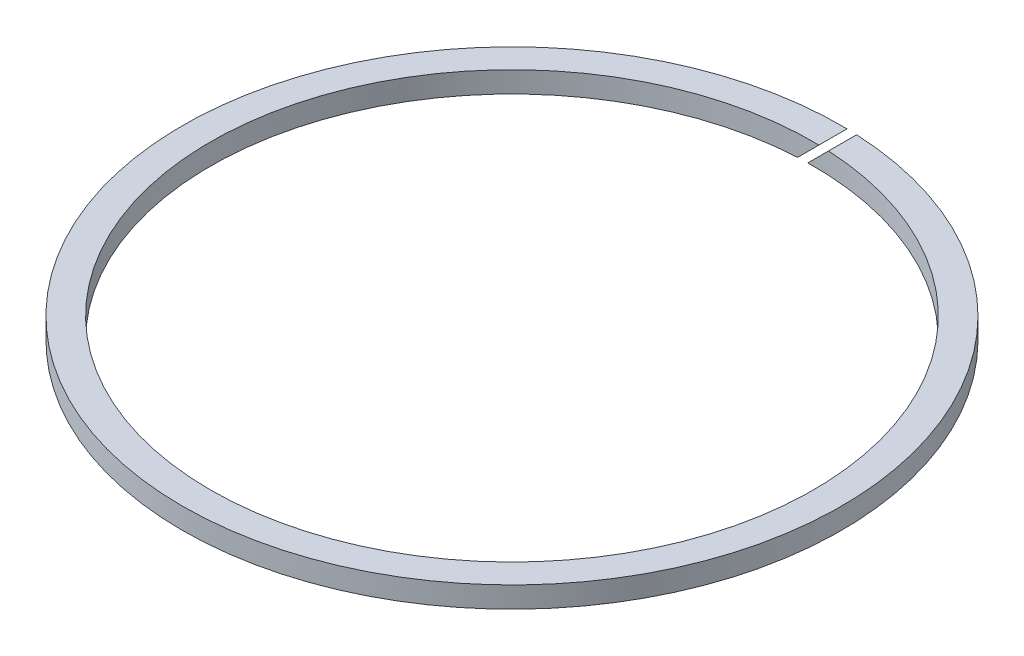
from build123d import *

# Parameters (mm, degrees)
SKETCH1_R           = 47
SKETCH1_R_2         = 43
BOSS_EXTRUDE1_DEPTH = 1.5
CUT_EXTRUDE1_DEPTH  = 48


with BuildPart() as part:
    # Sketch1 → Boss-Extrude1 (new body, symmetric)
    with BuildSketch(Plane(origin=(0, 0, 0), x_dir=(1, 0, 0), z_dir=(0, 1, 0))):
        Circle(SKETCH1_R)
        Circle(SKETCH1_R_2, mode=Mode.SUBTRACT)
    extrude(amount=BOSS_EXTRUDE1_DEPTH, both=True)

    # Sketch2 → Cut-Extrude1 (cut, through all)
    with BuildSketch(Plane.XY):
        Polygon((0.792893219, 1.5), (-2.207106781, -1.5), (-0.792893219, -1.5), (2.207106781, 1.5), align=None)
    extrude(amount=-CUT_EXTRUDE1_DEPTH, mode=Mode.SUBTRACT)


solid = part.part
